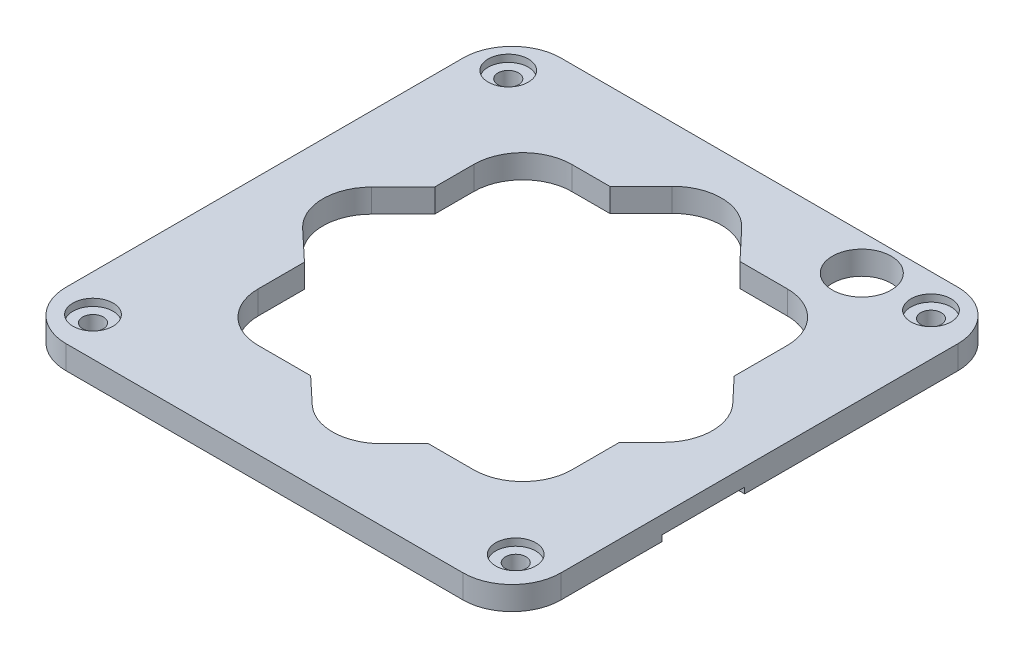
from build123d import *

# Parameters (mm, degrees)
EXTRUDE_1_DEPTH      = 2.4
SKETCH_2_R           = 1.05000254
CUT_EXTRUDE_1_DEPTH  = 10
CUT_EXTRUDE_8_DEPTH  = 3.4
SKETCH_4_R           = 2.05
CUT_EXTRUDE_9_DEPTH  = 0.73
SKETCH_5_R           = 3
CUT_EXTRUDE_10_DEPTH = 3.4
SKETCH_6_W           = 27.234219955
SKETCH_6_H           = 8.445318751
CUT_EXTRUDE_12_DEPTH = 0.6


with BuildPart() as part:
    # 草图1 → 凸台-拉伸1 (new body)
    with BuildSketch(Plane(origin=(0, 0, 0), x_dir=(1, 0, 0), z_dir=(0, 1, 0))):
        with BuildLine():
            Line((-20.25, 25.25), (20.25, 25.25))
            ThreePointArc((20.25, 25.25), (23.785533906, 23.785533906), (25.25, 20.25))
            Line((25.25, 20.25), (25.25, -20.25))
            ThreePointArc((25.25, -20.25), (23.785533906, -23.785533906), (20.25, -25.25))
            Line((20.25, -25.25), (-20.25, -25.25))
            ThreePointArc((-20.25, -25.25), (-23.785533906, -23.785533906), (-25.25, -20.25))
            Line((-25.25, -20.25), (-25.25, 20.25))
            ThreePointArc((-25.25, 20.25), (-23.785533906, 23.785533906), (-20.25, 25.25))
        make_face()
    extrude(amount=EXTRUDE_1_DEPTH)

    # 草图2 → 切除-拉伸1 (cut)
    with BuildSketch(Plane(origin=(0, 2.4, 0), x_dir=(1, 0, 0), z_dir=(0, 1, 0))):
        with Locations((21.308392177, -20.927391415)):
            Circle(SKETCH_2_R)
        with Locations((-21.452692405, -21.308392177)):
            Circle(SKETCH_2_R)
        with Locations((-21.833693167, 21.452692405)):
            Circle(SKETCH_2_R)
        with Locations((20.927391415, 21.833693167)):
            Circle(SKETCH_2_R)
    extrude(amount=-CUT_EXTRUDE_1_DEPTH, mode=Mode.SUBTRACT)

    # 草图3 → 切除-拉伸8 (cut, through all)
    with BuildSketch(Plane(origin=(0, 2.4, 0), x_dir=(1, 0, 0), z_dir=(0, 1, 0))):
        with BuildLine():
            Line((-18.515650574, 4.18369185), (-15.3, 7.427416998))
            Line((-15.3, 7.427416998), (-15.3, 11.4))
            ThreePointArc((-15.3, 11.4), (-13.835533906, 14.935533906), (-10.3, 16.4))
            Line((-10.3, 16.4), (-6.40507507, 16.4))
            Line((-6.40507507, 16.4), (-3.244074851, 19.588597663))
            ThreePointArc((-3.244074851, 19.588597663), (0.369210969, 21.068073973), (3.944434556, 19.49885096))
            Line((3.944434556, 19.49885096), (6.866728136, 16.4))
            Line((6.866728136, 16.4), (11.7, 16.4))
            ThreePointArc((11.7, 16.4), (15.235533906, 14.935533906), (16.7, 11.4))
            Line((16.7, 11.4), (16.7, 5.972627416))
            Line((16.7, 5.972627416), (19.047343924, 3.483463075))
            ThreePointArc((19.047343924, 3.483463075), (20.409425455, 0.000538557), (18.974455547, -3.452994511))
            Line((18.974455547, -3.452994511), (16.7, -5.765519402))
            Line((16.7, -5.765519402), (16.7, -10.6))
            ThreePointArc((16.7, -10.6), (15.235533906, -14.135533906), (11.7, -15.6))
            Line((11.7, -15.6), (7.027416998, -15.6))
            Line((7.027416998, -15.6), (4.702011711, -17.964327417))
            ThreePointArc((4.702011711, -17.964327417), (1.236457236, -19.457273038), (-2.285597178, -18.102988303))
            Line((-2.285597178, -18.102988303), (-4.950834187, -15.6))
            Line((-4.950834187, -15.6), (-10.3, -15.6))
            ThreePointArc((-10.3, -15.6), (-13.835533906, -14.135533906), (-15.3, -10.6))
            Line((-15.3, -10.6), (-15.3, -5.880848985))
            Line((-15.3, -5.880848985), (-18.387638433, -2.981173325))
            ThreePointArc((-18.387638433, -2.981173325), (-19.963985761, 0.57423879), (-18.515650574, 4.18369185))
        make_face()
    extrude(amount=-CUT_EXTRUDE_8_DEPTH, mode=Mode.SUBTRACT)

    # 草图4 → 切除-拉伸9 (cut)
    with BuildSketch(Plane(origin=(0, 2.4, 0), x_dir=(1, 0, 0), z_dir=(0, 1, 0))):
        with Locations((-21.833693167, 21.452692405)):
            Circle(SKETCH_4_R)
        with Locations((20.927391415, 21.833693167)):
            Circle(SKETCH_4_R)
        with Locations((21.308392177, -20.927391415)):
            Circle(SKETCH_4_R)
        with Locations((-21.452692405, -21.308392177)):
            Circle(SKETCH_4_R)
    extrude(amount=-CUT_EXTRUDE_9_DEPTH, mode=Mode.SUBTRACT)

    # 草图5 → 切除-拉伸10 (cut, through all)
    with BuildSketch(Plane(origin=(0, 2.4, 0), x_dir=(1, 0, 0), z_dir=(0, 1, 0))):
        with Locations((14.107378715, 21.590614681)):
            Circle(SKETCH_5_R)
    extrude(amount=-CUT_EXTRUDE_10_DEPTH, mode=Mode.SUBTRACT)

    # 草图6 → 切除-拉伸12 (cut)
    with BuildSketch(Plane.XZ):
        with Locations((26.071380204, 5.725361951)):
            Rectangle(SKETCH_6_W, SKETCH_6_H)
    extrude(amount=-CUT_EXTRUDE_12_DEPTH, mode=Mode.SUBTRACT)


solid = part.part
